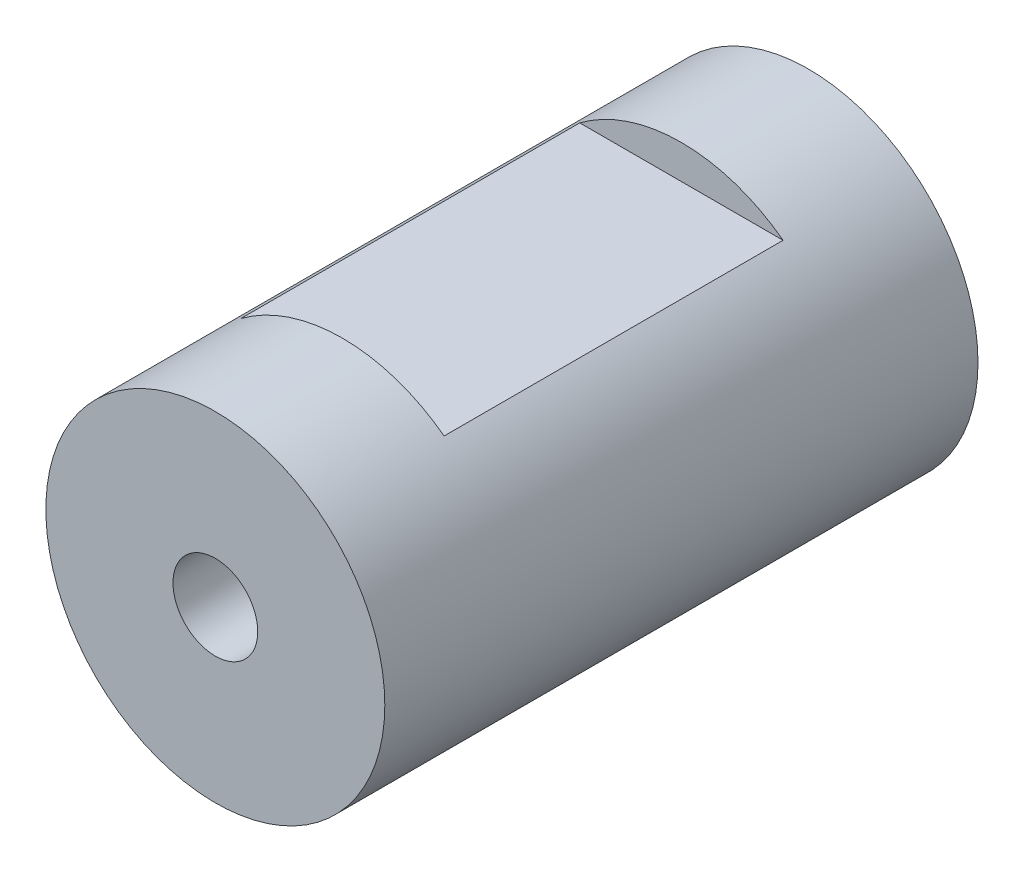
from build123d import *

# Parameters (mm, degrees)
SKETCH1_R               = 20
BOSS_EXTRUDE1_DEPTH     = 35
SKETCH3_R               = 5
SKETCH4_W               = 40
SKETCH4_H               = 4
CUT_EXTRUDE1_DEPTH      = 21
CUT_EXTRUDE1_DEPTH_BACK = 21


with BuildPart() as part:
    # Sketch1 → Boss-Extrude1 (new body, symmetric)
    with BuildSketch(Plane.XY):
        Circle(SKETCH1_R)
    extrude(amount=BOSS_EXTRUDE1_DEPTH, both=True)

    # Cut-Sweep1: sweep along a path in Sketch2
    with BuildLine(Plane(origin=(0, 0, 0), x_dir=(1, 0, 0), z_dir=(0, 1, 0))) as cut_sweep1_path:
        Line((0, 35), (0, 10))
        Line((0, 10), (12, 10))
        Line((12, 10), (12, -10))
        Line((12, -10), (0, -10))
        Line((0, -10), (0, -35))
    # Sketch3 → Cut-Sweep1 (sweep, cut)
    with BuildSketch(Plane.XY.offset(35)):
        Circle(SKETCH3_R)
    sweep(path=cut_sweep1_path.line, transition=Transition.RIGHT, mode=Mode.SUBTRACT)

    # Sketch4 → Cut-Extrude1 (cut, two sides)
    with BuildSketch(Plane(origin=(0, 0, 0), x_dir=(0, 0, -1), z_dir=(1, 0, 0))) as cut_extrude1_sk:
        with Locations((0, 18)):
            Rectangle(SKETCH4_W, SKETCH4_H)
    extrude(amount=CUT_EXTRUDE1_DEPTH, mode=Mode.SUBTRACT)
    extrude(cut_extrude1_sk.sketch, amount=-CUT_EXTRUDE1_DEPTH_BACK, mode=Mode.SUBTRACT)


solid = part.part
